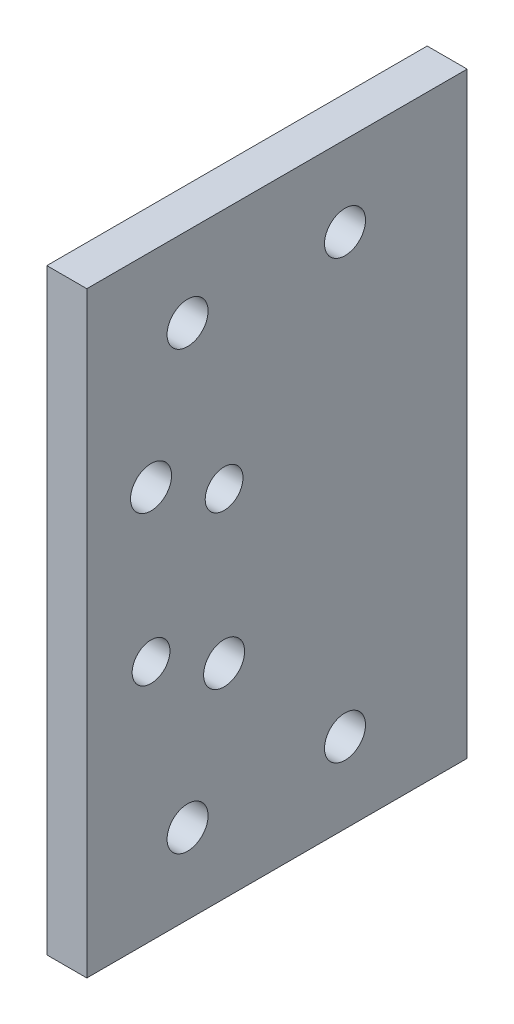
from build123d import *

# Parameters (mm, degrees)
SKETCH1_R           = 3
SKETCH1_R_2         = 3.25755
BOSS_EXTRUDE1_DEPTH = 6.35
SKETCH2_W           = 94.8
SKETCH2_H           = 25.4
CUT_EXTRUDE1_DEPTH  = 6.35


with BuildPart() as part:
    # Sketch1 → Boss-Extrude1 (new body)
    with BuildSketch(Plane.YZ):
        Polygon((-47.4, -25), (-47.4, -69.8), (47.4, -69.8), (47.4, 16), (-47.4, 16), align=None)
        with Locations((-9, 5.8)):
            Circle(SKETCH1_R, mode=Mode.SUBTRACT)
        with Locations((-15, -5.8)):
            Circle(SKETCH1_R_2, mode=Mode.SUBTRACT)
        with Locations((9, -5.8)):
            Circle(SKETCH1_R, mode=Mode.SUBTRACT)
        with Locations((15, 5.8)):
            Circle(SKETCH1_R_2, mode=Mode.SUBTRACT)
        with Locations((-34.7, -57.1)):
            Circle(SKETCH1_R_2, mode=Mode.SUBTRACT)
        with Locations((34.7, -57.1)):
            Circle(SKETCH1_R_2, mode=Mode.SUBTRACT)
        with Locations((-34.7, -25)):
            Circle(SKETCH1_R_2, mode=Mode.SUBTRACT)
        with Locations((-34.7, 0)):
            Circle(SKETCH1_R_2, mode=Mode.SUBTRACT)
        with Locations((34.7, 0)):
            Circle(SKETCH1_R_2, mode=Mode.SUBTRACT)
        with Locations((34.7, -25)):
            Circle(SKETCH1_R_2, mode=Mode.SUBTRACT)
    extrude(amount=BOSS_EXTRUDE1_DEPTH)

    # Sketch2 → Cut-Extrude1 (cut)
    with BuildSketch(Plane.YZ.offset(6.35)):
        with Locations((0, -57.1)):
            Rectangle(SKETCH2_W, SKETCH2_H)
    extrude(amount=-CUT_EXTRUDE1_DEPTH, mode=Mode.SUBTRACT)


solid = part.part
